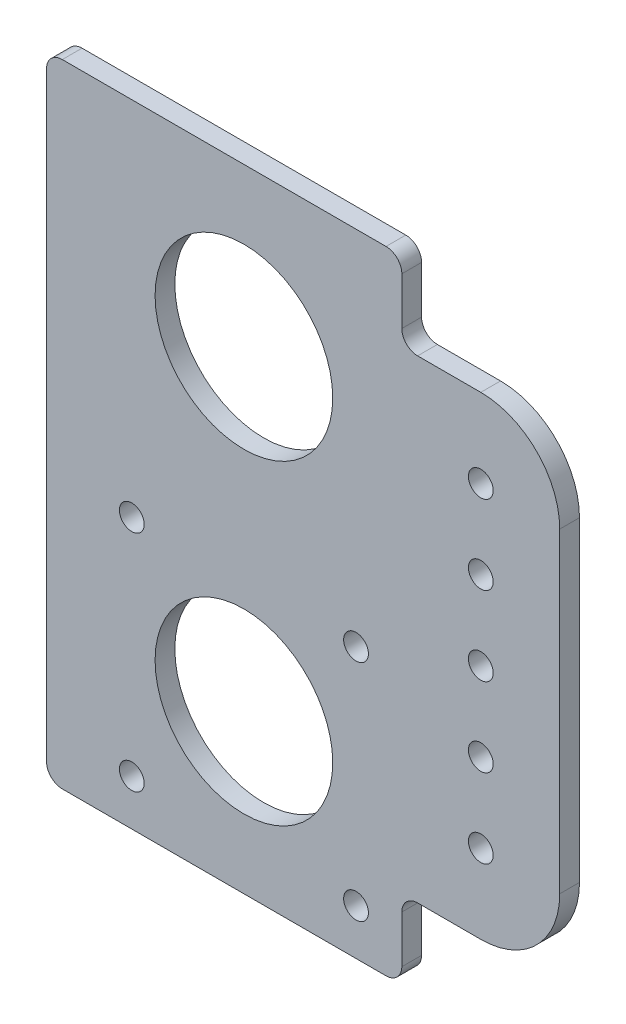
from build123d import *

# Parameters (mm, degrees)
SKETCH1_R           = 1.9939
SKETCH1_R_2         = 14.2875
BOSS_EXTRUDE1_DEPTH = 3.175
FILLET1_R           = 2.54


with BuildPart() as part:
    # Sketch1 → Boss-Extrude1 (new body)
    with BuildSketch(Plane.XY):
        with BuildLine():
            Line((25.4, 76.2), (-31.75, 76.2))
            Line((-31.75, 76.2), (-31.75, -25.4))
            Line((-31.75, -25.4), (25.4, -25.4))
            Line((25.4, -25.4), (25.4, -12.7))
            Line((25.4, -12.7), (38.1, -12.7))
            ThreePointArc((38.1, -12.7), (47.080256121, -8.980256121), (50.8, 0))
            Line((50.8, 0), (50.8, 50.8))
            ThreePointArc((50.8, 50.8), (47.080256121, 59.780256121), (38.1, 63.5))
            Line((38.1, 63.5), (25.4, 63.5))
            Line((25.4, 63.5), (25.4, 76.2))
        make_face()
        with Locations((-18.034, -18.034)):
            Circle(SKETCH1_R, mode=Mode.SUBTRACT)
        with Locations((-18.034, 18.034)):
            Circle(SKETCH1_R, mode=Mode.SUBTRACT)
        Circle(SKETCH1_R_2, mode=Mode.SUBTRACT)
        with Locations((18.034, -18.034)):
            Circle(SKETCH1_R, mode=Mode.SUBTRACT)
        with Locations((18.034, 18.034)):
            Circle(SKETCH1_R, mode=Mode.SUBTRACT)
        with Locations((38.1, 0)):
            Circle(SKETCH1_R, mode=Mode.SUBTRACT)
        with Locations((38.1, 12.7)):
            Circle(SKETCH1_R, mode=Mode.SUBTRACT)
        with Locations((0, 50.8)):
            Circle(SKETCH1_R_2, mode=Mode.SUBTRACT)
        with Locations((38.1, 25.4)):
            Circle(SKETCH1_R, mode=Mode.SUBTRACT)
        with Locations((38.1, 38.1)):
            Circle(SKETCH1_R, mode=Mode.SUBTRACT)
        with Locations((38.1, 50.8)):
            Circle(SKETCH1_R, mode=Mode.SUBTRACT)
    extrude(amount=BOSS_EXTRUDE1_DEPTH)

    # Fillet1
    fillet1_edges = [part.edges().sort_by_distance(p)[0] for p in [
        (25.4, -12.7, 1.5875),
        (25.4, -25.4, 1.5875),
        (-31.75, -25.4, 1.5875),
        (-31.75, 76.2, 1.5875),
        (25.4, 76.2, 1.5875),
        (25.4, 63.5, 1.5875),
    ]]
    fillet(fillet1_edges, radius=FILLET1_R)


solid = part.part
